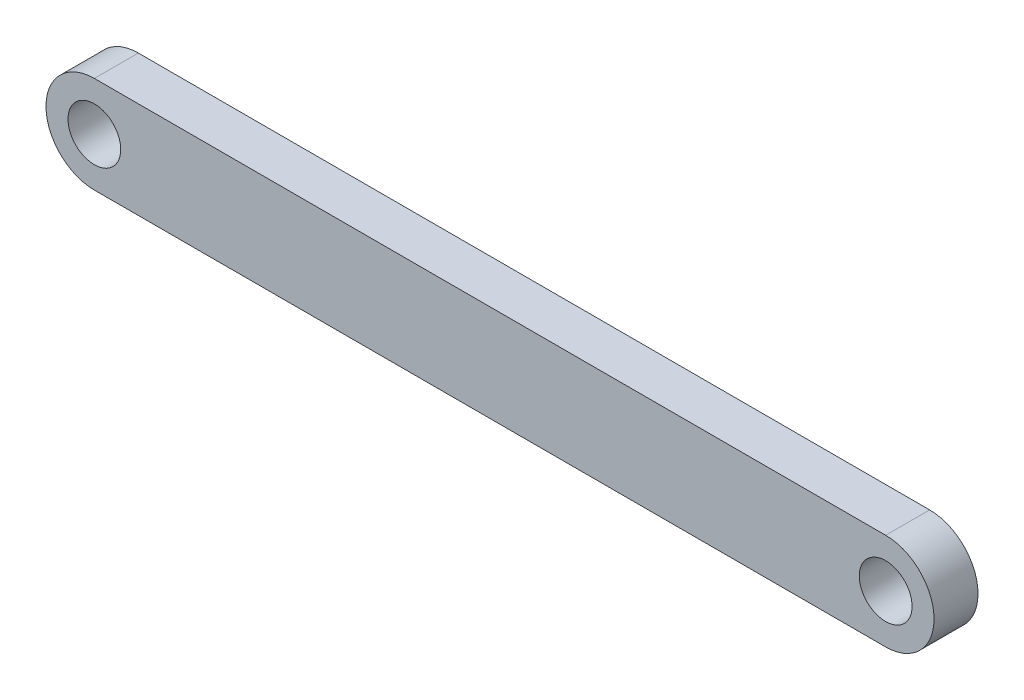
from build123d import *

# Parameters (mm, degrees)
SKETCH1_R           = 3
BOSS_EXTRUDE1_DEPTH = 2.5


with BuildPart() as part:
    # Sketch1 → Boss-Extrude1 (new body, symmetric)
    with BuildSketch(Plane.XY):
        with BuildLine():
            Line((-45, 5.5), (45, 5.5))
            ThreePointArc((45, 5.5), (50.5, 0), (45, -5.5))
            Line((45, -5.5), (-45, -5.5))
            ThreePointArc((-45, -5.5), (-50.5, 0), (-45, 5.5))
        make_face()
        with Locations((-45, 0)):
            Circle(SKETCH1_R, mode=Mode.SUBTRACT)
        with Locations((45, 0)):
            Circle(SKETCH1_R, mode=Mode.SUBTRACT)
    extrude(amount=BOSS_EXTRUDE1_DEPTH, both=True)


solid = part.part
